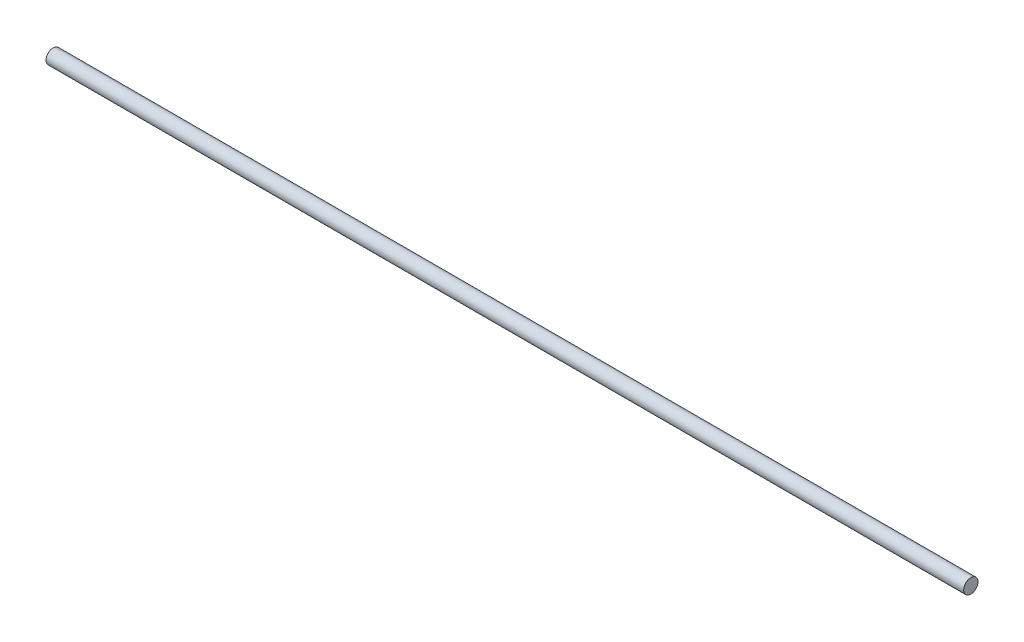
from build123d import *

# Parameters (mm, degrees)
SWEEP1_PROFILE_R = 9.525


with BuildPart() as part:
    # Sweep1: sweep along a path in Sketch1
    with BuildLine(Plane(origin=(0, 0, 0), x_dir=(1, 0, 0), z_dir=(0, 1, 0))) as sweep1_path:
        Line((0, 0), (-1219.2, 0))
    # Sweep1 profile (on start of the path) → Sweep1 (sweep)
    with BuildSketch(Plane(origin=(0, 0, 0), x_dir=(0, 0, -1), z_dir=(-1, 0, 0))):
        Circle(SWEEP1_PROFILE_R)
    sweep(path=sweep1_path.line)


solid = part.part
